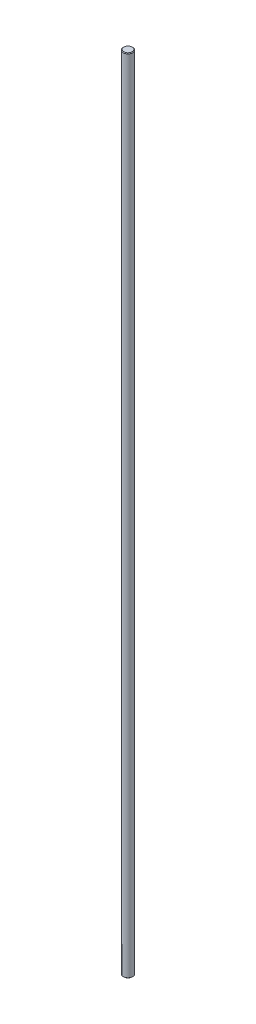
from build123d import *

# Parameters (mm, degrees)
CROQUIS1_R              = 4
SALIENTE_EXTRUIR1_DEPTH = 675
CHAFL_N1_SIZE           = 0.5


with BuildPart() as part:
    # Croquis1 → Saliente-Extruir1 (new body)
    with BuildSketch(Plane(origin=(0, 0, 0), x_dir=(1, 0, 0), z_dir=(0, 1, 0))):
        Circle(CROQUIS1_R)
    extrude(amount=SALIENTE_EXTRUIR1_DEPTH)

    # Chaflán1
    chafl_n1_edges = [part.edges().sort_by_distance(p)[0] for p in [
        (-4, 0, 0),
        (-4, 675, 0),
    ]]
    chamfer(chafl_n1_edges, length=CHAFL_N1_SIZE)


solid = part.part
